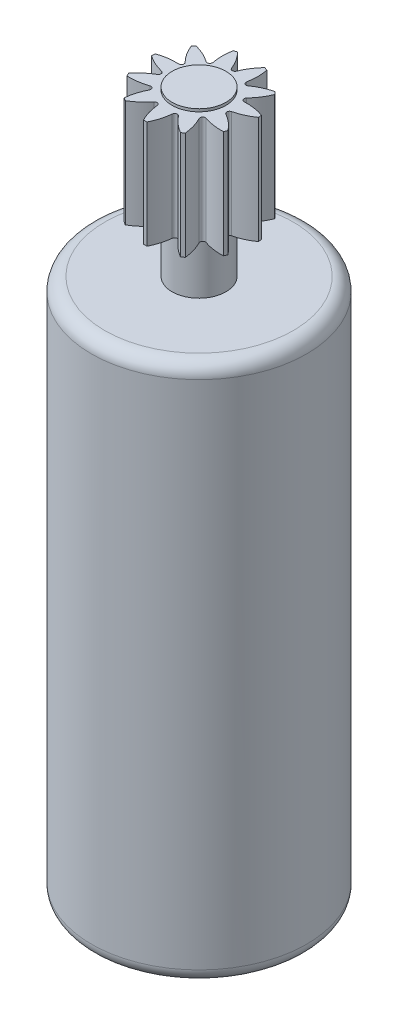
from build123d import *

# Parameters (mm, degrees)
FILLET1_R          = 0.5
CUT_EXTRUDE1_DEPTH = 4
CIRPATTERN1_COUNT  = 11


with BuildPart() as part:
    # Sketch1 → Revolve1 (revolve)
    with BuildSketch(Plane.XY):
        Polygon((0, 0), (0, 26.1), (1, 26.1), (1, 26), (2, 26), (2, 22), (1, 22), (1, 20), (4, 20), (4, 0), align=None)
    revolve(axis=Axis((0, 0, 0), (0, 1, 0)))

    # Fillet1
    fillet1_edges = [part.edges().sort_by_distance(p)[0] for p in [
        (-4, 20, 0),
        (-4, 0, 0),
    ]]
    fillet(fillet1_edges, radius=FILLET1_R)

    # Sketch2 → Cut-Extrude1 (cut)
    with BuildSketch(Plane(origin=(0, 26, 0), x_dir=(1, 0, 0), z_dir=(0, 1, 0))):
        with BuildLine():
            ThreePointArc((-0.5, 1.936491673), (-0.266119458, 1.637619869), (-0.092905413, 1.299949383))
            ThreePointArc((-0.092905413, 1.299949383), (0, 1.236943764), (0.092905413, 1.299949383))
            ThreePointArc((0.092905413, 1.299949383), (0.266119458, 1.637619869), (0.5, 1.936491673))
            ThreePointArc((0.5, 1.936491673), (0, 2), (-0.5, 1.936491673))
        make_face()
    cut_extrude1 = extrude(amount=-CUT_EXTRUDE1_DEPTH, mode=Mode.SUBTRACT)

    # CirPattern1: Cut-Extrude1 ×11 about axis
    cirpattern1_axis = Axis((0, 0, 0), (0, 1, 0))
    for i in range(1, CIRPATTERN1_COUNT):
        add(cut_extrude1.rotate(cirpattern1_axis, i * 360 / CIRPATTERN1_COUNT), mode=Mode.SUBTRACT)


solid = part.part
